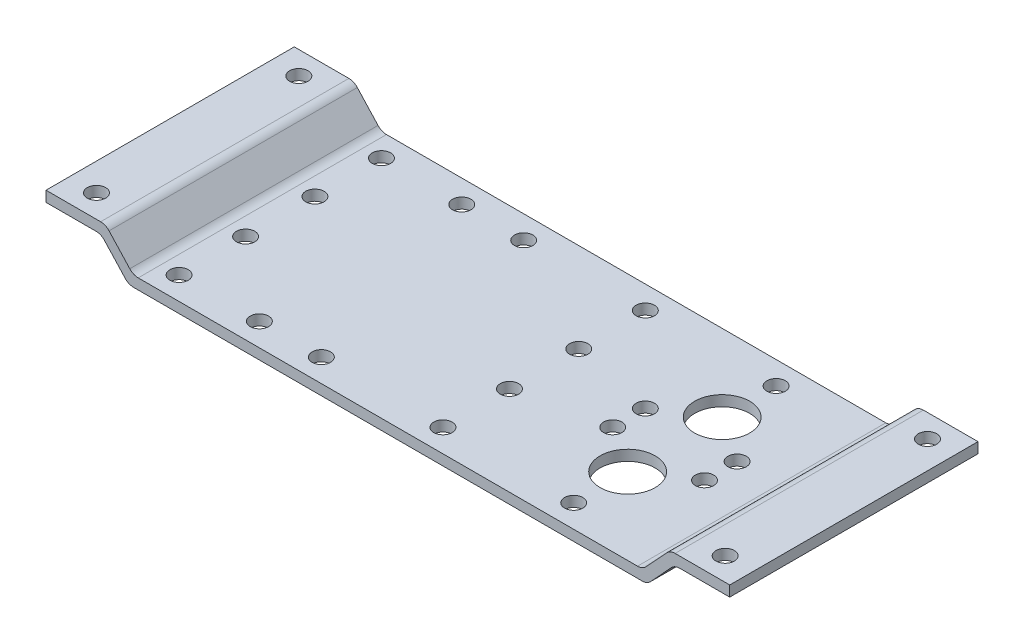
from build123d import *

# Parameters (mm, degrees)
BOSS_EXTRU_1_DEPTH      = 54.1
ESQUISSE2_R             = 2
ESQUISSE2_R_2           = 6
ENL_V_MAT_EXTRU_1_DEPTH = 9.8


with BuildPart() as part:
    # Esquisse1 → Boss.-Extru.1 (new body)
    with BuildSketch(Plane.XY):
        with BuildLine():
            Line((0, 0), (11.905421921, 0))
            ThreePointArc((11.905421921, 0), (12.908105659, -0.209885304), (13.742430532, -0.804299743))
            Line((13.742430532, -0.804299743), (18.257569468, -5.695700257))
            ThreePointArc((18.257569468, -5.695700257), (19.091894341, -6.290114696), (20.094578079, -6.5))
            Line((20.094578079, -6.5), (128.905421921, -6.5))
            ThreePointArc((128.905421921, -6.5), (129.908105659, -6.290114696), (130.742430532, -5.695700257))
            Line((130.742430532, -5.695700257), (135.257569468, -0.804299743))
            ThreePointArc((135.257569468, -0.804299743), (136.091894341, -0.209885304), (137.094578079, 0))
            Line((137.094578079, 0), (149, 0))
            Line((149, 0), (149, -2.3))
            Line((149, -2.3), (138.101589912, -2.3))
            ThreePointArc((138.101589912, -2.3), (137.098906174, -2.509885304), (136.264581301, -3.104299743))
            Line((136.264581301, -3.104299743), (131.749442365, -7.995700257))
            ThreePointArc((131.749442365, -7.995700257), (130.915117492, -8.590114696), (129.912433754, -8.8))
            Line((129.912433754, -8.8), (19.087566246, -8.8))
            ThreePointArc((19.087566246, -8.8), (18.084882508, -8.590114696), (17.250557635, -7.995700257))
            Line((17.250557635, -7.995700257), (12.735418699, -3.104299743))
            ThreePointArc((12.735418699, -3.104299743), (11.901093826, -2.509885304), (10.898410088, -2.3))
            Line((10.898410088, -2.3), (0, -2.3))
            Line((0, -2.3), (0, 0))
        make_face()
    extrude(amount=BOSS_EXTRU_1_DEPTH)

    # Esquisse2 → Enlèv. mat.-Extru.1 (cut, through all)
    with BuildSketch(Plane(origin=(0, 0, 0), x_dir=(1, 0, 0), z_dir=(0, 1, 0))):
        with Locations((6, -5)):
            Circle(ESQUISSE2_R)
        with Locations((24, -5)):
            Circle(ESQUISSE2_R)
        with Locations((41.5, -5)):
            Circle(ESQUISSE2_R)
        with Locations((55, -5)):
            Circle(ESQUISSE2_R)
        with Locations((81.5, -5)):
            Circle(ESQUISSE2_R)
        with Locations((110, -5)):
            Circle(ESQUISSE2_R)
        with Locations((143, -5)):
            Circle(ESQUISSE2_R)
        with Locations((120, -30.6)):
            Circle(ESQUISSE2_R)
        with Locations((100, -30.6)):
            Circle(ESQUISSE2_R)
        with Locations((110, -37.35)):
            Circle(ESQUISSE2_R_2)
        with Locations((81.5, -34.6)):
            Circle(ESQUISSE2_R)
        with Locations((24, -34.6)):
            Circle(ESQUISSE2_R)
        with Locations((143, -49.1)):
            Circle(ESQUISSE2_R)
        with Locations((110, -49.1)):
            Circle(ESQUISSE2_R)
        with Locations((24, -19.5)):
            Circle(ESQUISSE2_R)
        with Locations((81.5, -19.5)):
            Circle(ESQUISSE2_R)
        with Locations((110, -16.75)):
            Circle(ESQUISSE2_R_2)
        with Locations((120, -23.5)):
            Circle(ESQUISSE2_R)
        with Locations((100, -23.5)):
            Circle(ESQUISSE2_R)
        with Locations((81.5, -49.1)):
            Circle(ESQUISSE2_R)
        with Locations((55, -49.1)):
            Circle(ESQUISSE2_R)
        with Locations((41.5, -49.1)):
            Circle(ESQUISSE2_R)
        with Locations((24, -49.1)):
            Circle(ESQUISSE2_R)
        with Locations((6, -49.1)):
            Circle(ESQUISSE2_R)
    extrude(amount=-ENL_V_MAT_EXTRU_1_DEPTH, mode=Mode.SUBTRACT)


solid = part.part
